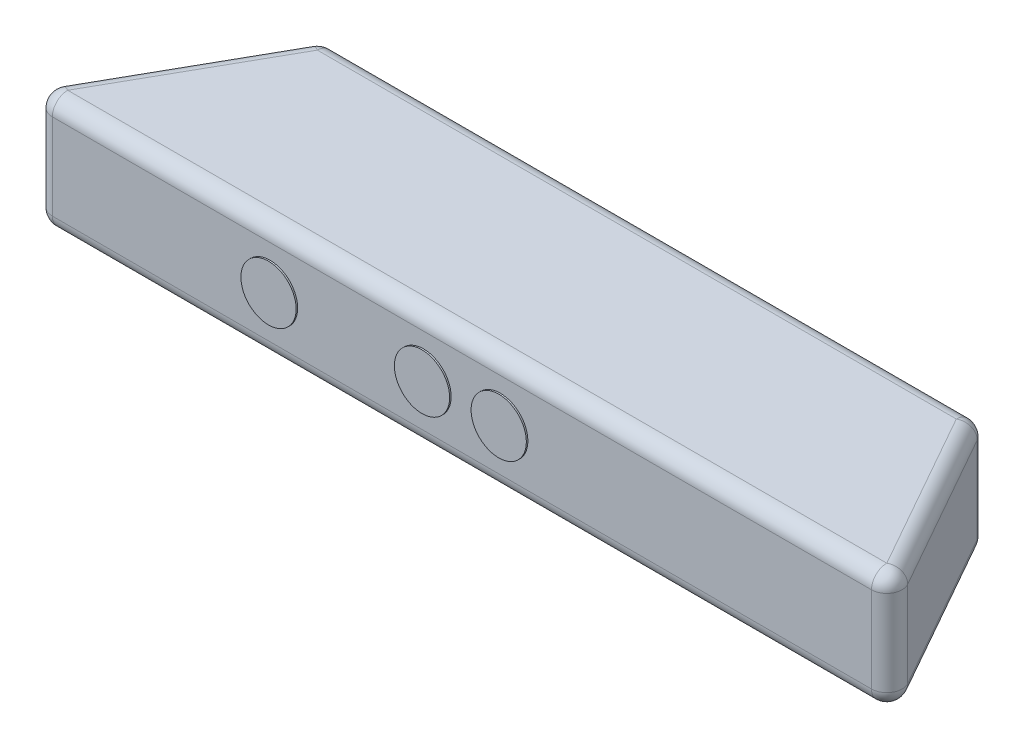
from build123d import *

# Parameters (mm, degrees)
BOSS_EXTRUDE1_DEPTH = 38
BOSS_EXTRUDE2_DEPTH = 10
FILLET1_R           = 5
SKETCH3_R           = 9
CUT_EXTRUDE1_DEPTH  = 5
SKETCH5_R           = 9
BOSS_EXTRUDE3_DEPTH = 0.5
SKETCH6_R           = 3
CUT_EXTRUDE2_DEPTH  = 2.5


with BuildPart() as part:
    # Sketch1 → Boss-Extrude1 (new body)
    with BuildSketch(Plane(origin=(0, 0, 0), x_dir=(1, 0, 0), z_dir=(0, 1, 0))):
        Polygon((-142, 0), (142, 0), (107, 62), (-107, 62), align=None)
    extrude(amount=BOSS_EXTRUDE1_DEPTH)

    # Sketch2 → Boss-Extrude2 (add)
    with BuildSketch(Plane.XZ):
        with BuildLine():
            ThreePointArc((8.5, -31), (0, -35.75), (-8.5, -31))
            ThreePointArc((-8.5, -31), (0, -26.25), (8.5, -31))
        make_face()
    extrude(amount=BOSS_EXTRUDE2_DEPTH)

    # Fillet1
    fillet1_edges = [part.edges().sort_by_distance(p)[0] for p in [
        (124.5, 38, -31),
        (0, 38, -62),
        (-124.5, 38, -31),
        (0, 0, -62),
        (124.5, 0, -31),
        (0, 0, 0),
        (-124.5, 0, -31),
        (0, 38, 0),
        (-107, 19, -62),
        (107, 19, -62),
        (142, 19, 0),
        (-142, 19, 0),
    ]]
    fillet(fillet1_edges, radius=FILLET1_R)

    # Sketch3 → Cut-Extrude1 (cut)
    with BuildSketch(Plane.XY):
        with Locations((12.5, 19)):
            Circle(SKETCH3_R)
        with Locations((-12.5, 19)):
            Circle(SKETCH3_R)
        with Locations((-62.5, 19)):
            Circle(SKETCH3_R)
    extrude(amount=-CUT_EXTRUDE1_DEPTH, mode=Mode.SUBTRACT)

    # Sketch5 → Boss-Extrude3 (add, symmetric)
    with BuildSketch(Plane.XY):
        with Locations((-12.5, 19)):
            Circle(SKETCH5_R)
        with Locations((12.5, 19)):
            Circle(SKETCH5_R)
        with Locations((-62.5, 19)):
            Circle(SKETCH5_R)
    extrude(amount=BOSS_EXTRUDE3_DEPTH, both=True)

    # Sketch6 → Cut-Extrude2 (cut)
    with BuildSketch(Plane.XZ):
        with Locations((-97, -17.5)):
            Circle(SKETCH6_R)
        with Locations((97, -17.5)):
            Circle(SKETCH6_R)
    extrude(amount=-CUT_EXTRUDE2_DEPTH, mode=Mode.SUBTRACT)


solid = part.part
